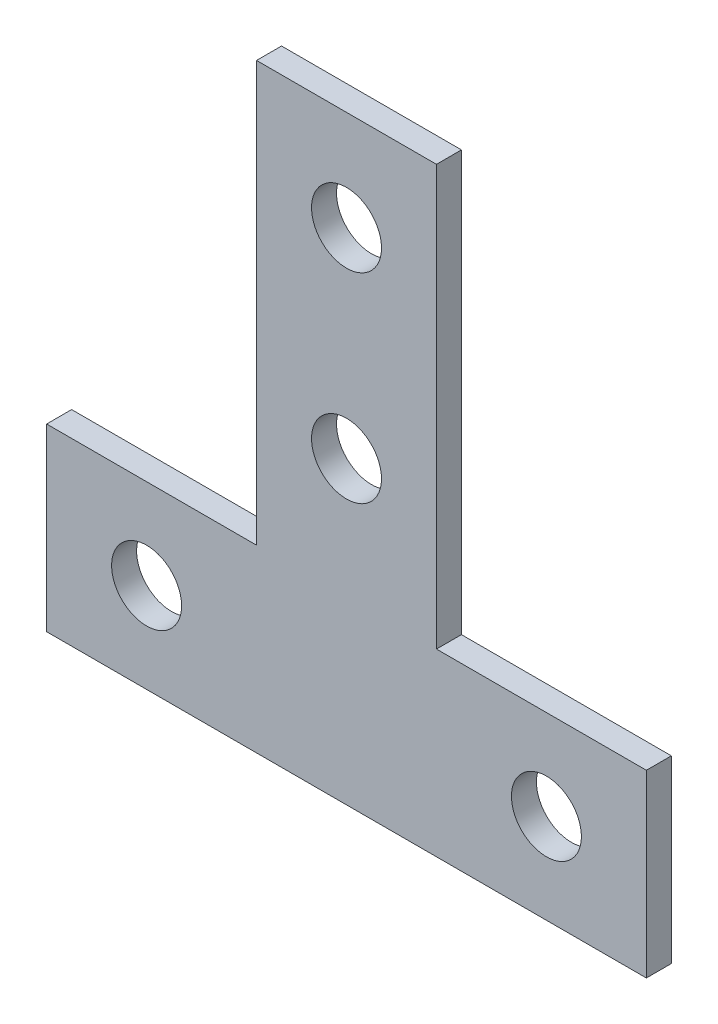
from build123d import *

# Parameters (mm, degrees)
SKETCH_1_R      = 3.5
EXTRUDE_1_DEPTH = 2.5


with BuildPart() as part:
    # Эскиз1 → Бобышка-Вытянуть1 (new body)
    with BuildSketch(Plane.XY):
        Polygon((-30, 0), (30, 0), (30, 18), (9, 18), (9, 60), (-9, 60), (-9, 18), (-30, 18), align=None)
        with Locations((0, 50)):
            Circle(SKETCH_1_R, mode=Mode.SUBTRACT)
        with Locations((0, 30)):
            Circle(SKETCH_1_R, mode=Mode.SUBTRACT)
        with Locations((-20, 9)):
            Circle(SKETCH_1_R, mode=Mode.SUBTRACT)
        with Locations((20, 9)):
            Circle(SKETCH_1_R, mode=Mode.SUBTRACT)
    extrude(amount=EXTRUDE_1_DEPTH)


solid = part.part
